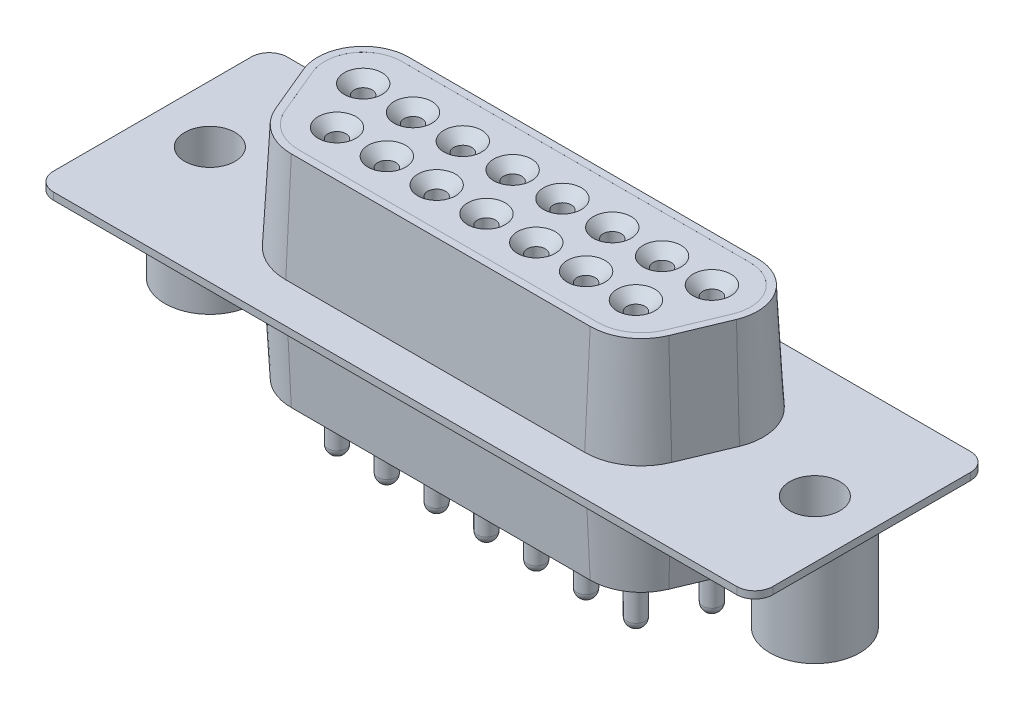
from build123d import *

# Parameters (mm, degrees)
BASE_EXTRUDE_DEPTH           = 5.91
BASE_EXTRUDE_DRAFT           = 3
BOSS_EXTRUDE1_DEPTH          = 0.2
CUT_EXTRUDE1_DEPTH           = 0.001
SKETCH4_R                    = 0.5
CUT_EXTRUDE5_DEPTH           = 6
SKETCH5_R                    = 0.5
BOSS_EXTRUDE5_DEPTH          = 3
DOME3_FACE_RADIUS            = 0.5
DOME3_HEIGHT                 = 0.5
CHAMFER1_SIZE                = 0.55
LPATTERN1_COUNT              = 8
LPATTERN1_PITCH              = 2.77
LPATTERN1_COPY_1_FACE_RADIUS = 0.5
LPATTERN1_COPY_1_HEIGHT      = 0.5
LPATTERN1_COPY_2_FACE_RADIUS = 0.5
LPATTERN1_COPY_2_HEIGHT      = 0.5
LPATTERN1_COPY_3_FACE_RADIUS = 0.5
LPATTERN1_COPY_3_HEIGHT      = 0.5
LPATTERN1_COPY_4_FACE_RADIUS = 0.5
LPATTERN1_COPY_4_HEIGHT      = 0.5
LPATTERN1_COPY_5_FACE_RADIUS = 0.5
LPATTERN1_COPY_5_HEIGHT      = 0.5
LPATTERN1_COPY_6_FACE_RADIUS = 0.5
LPATTERN1_COPY_6_HEIGHT      = 0.5
LPATTERN1_COPY_7_FACE_RADIUS = 0.5
LPATTERN1_COPY_7_HEIGHT      = 0.5
CHAMFER1_OF_LPATTERN1_SIZE   = 0.55
SKETCH6_R                    = 0.5
CUT_EXTRUDE8_DEPTH           = 6
SKETCH7_R                    = 0.5
BOSS_EXTRUDE6_DEPTH          = 3
DOME4_FACE_RADIUS            = 0.5
DOME4_HEIGHT                 = 0.5
CHAMFER3_SIZE                = 0.55
LPATTERN3_COUNT              = 7
LPATTERN3_PITCH              = 2.77
LPATTERN3_COPY_1_FACE_RADIUS = 0.5
LPATTERN3_COPY_1_HEIGHT      = 0.5
LPATTERN3_COPY_2_FACE_RADIUS = 0.5
LPATTERN3_COPY_2_HEIGHT      = 0.5
LPATTERN3_COPY_3_FACE_RADIUS = 0.5
LPATTERN3_COPY_3_HEIGHT      = 0.5
LPATTERN3_COPY_4_FACE_RADIUS = 0.5
LPATTERN3_COPY_4_HEIGHT      = 0.5
LPATTERN3_COPY_5_FACE_RADIUS = 0.5
LPATTERN3_COPY_5_HEIGHT      = 0.5
LPATTERN3_COPY_6_FACE_RADIUS = 0.5
LPATTERN3_COPY_6_HEIGHT      = 0.5
CHAMFER3_OF_LPATTERN3_SIZE   = 0.55
SKETCH8_R                    = 2.5
BOSS_EXTRUDE4_DEPTH          = 5.9
SKETCH9_R                    = 1.4
CUT_EXTRUDE4_DEPTH           = 34.06967682


with BuildPart() as part:
    # Sketch1 → Base-Extrude (with draft: the straight prism first)
    with BuildSketch(Plane(origin=(0, 0, 0), x_dir=(1, 0, 0), z_dir=(0, 1, 0))):
        with BuildLine():
            ThreePointArc((0, 2.54), (-2.113784333, 1.408373457), (-2.344092715, -0.97817654))
            Line((-2.344092715, -0.97817654), (-1.23595406, -3.633709202))
            ThreePointArc((-1.23595406, -3.633709202), (-0.189716779, -4.9034439), (1.385, -5.38))
            Line((1.385, -5.38), (18.005, -5.38))
            ThreePointArc((18.005, -5.38), (19.579716779, -4.9034439), (20.62595406, -3.633709202))
            Line((20.62595406, -3.633709202), (21.734092715, -0.97817654))
            ThreePointArc((21.734092715, -0.97817654), (21.503784333, 1.408373457), (19.39, 2.54))
            Line((19.39, 2.54), (0, 2.54))
        make_face()
    extrude(amount=-BASE_EXTRUDE_DEPTH)
    # Base-Extrude: the draft: its side faces are tilted about the plane it starts from
    base_extrude_sides = [part.faces().sort_by_distance(p)[0] for p in [
        (9.695, -2.955, -2.54),
        (-2.113784333, -2.955, -1.408373457),
        (-1.790023387, -2.955, 2.305942871),
        (-0.189716779, -2.955, 4.9034439),
        (9.695, -2.955, 5.38),
        (19.579716779, -2.955, 4.9034439),
        (21.180023387, -2.955, 2.305942871),
        (21.503784333, -2.955, -1.408373457),
    ]]
    draft(base_extrude_sides, Plane(origin=(0, 0, 0), x_dir=(1, 0, 0), z_dir=(0, 1, 0)), BASE_EXTRUDE_DRAFT)

    # Sketch2 → Boss-Extrude1 (add)
    with BuildSketch(Plane.XZ.offset(5.91)):
        with BuildLine():
            Line((28.695, 7.92), (-9.305, 7.92))
            ThreePointArc((-9.305, 7.92), (-10.012106781, 7.627106781), (-10.305, 6.92))
            Line((-10.305, 6.92), (-10.305, -4.08))
            ThreePointArc((-10.305, -4.08), (-10.012106781, -4.787106781), (-9.305, -5.08))
            Line((-9.305, -5.08), (28.695, -5.08))
            ThreePointArc((28.695, -5.08), (29.402106781, -4.787106781), (29.695, -4.08))
            Line((29.695, -4.08), (29.695, 6.92))
            ThreePointArc((29.695, 6.92), (29.402106781, 7.627106781), (28.695, 7.92))
        make_face()
    extrude(amount=BOSS_EXTRUDE1_DEPTH)

    # Sketch3 → Cut-Extrude1 (cut)
    with BuildSketch(Plane(origin=(0, 0, 0), x_dir=(-1, 0, 0), z_dir=(0, 1, 0))):
        with BuildLine():
            Line((-19.39, -2.14), (0, -2.14))
            ThreePointArc((0, -2.14), (1.78090491, -1.186582362), (1.974944256, 0.82413299))
            Line((1.974944256, 0.82413299), (0.8668056, 3.479665652))
            ThreePointArc((0.8668056, 3.479665652), (-0.032074317, 4.570564477), (-1.385, 4.98))
            Line((-1.385, 4.98), (-18.005, 4.98))
            ThreePointArc((-18.005, 4.98), (-19.357925683, 4.570564477), (-20.2568056, 3.479665652))
            Line((-20.2568056, 3.479665652), (-21.364944256, 0.82413299))
            ThreePointArc((-21.364944256, 0.82413299), (-21.17090491, -1.186582362), (-19.39, -2.14))
        make_face()
    extrude(amount=-CUT_EXTRUDE1_DEPTH, mode=Mode.SUBTRACT)

    # Boss-Mirror1: part across plane


with BuildPart() as part_1:
    add(part.part)
    add(part.part.mirror(Plane(origin=(28.695, -6.11, 6.92), x_dir=(0, 0, 1), z_dir=(0, -1, 0))))

    # Sketch4 → Cut-Extrude5 (cut)
    with BuildSketch(Plane(origin=(0, -0.001, 0), x_dir=(-1, 0, 0), z_dir=(0, 1, 0))):
        with Locations(Location((0, 0, 0), (0, 0, 90))):
            Circle(SKETCH4_R)
    cut_extrude5 = extrude(amount=-CUT_EXTRUDE5_DEPTH, mode=Mode.SUBTRACT)

    # Sketch5 → Boss-Extrude5 (add)
    with BuildSketch(Plane.XZ.offset(12.219)):
        with Locations(Location((0, 0, 0), (0, 0, 90))):
            Circle(SKETCH5_R)
    boss_extrude5 = extrude(amount=BOSS_EXTRUDE5_DEPTH)

    # Dome3: a dome of height H over a round flat face of radius A is a cap of a sphere of radius (A * A + H * H) / (2 * H)
    dome3_r = (DOME3_FACE_RADIUS * DOME3_FACE_RADIUS + DOME3_HEIGHT * DOME3_HEIGHT) / (2 * DOME3_HEIGHT)
    dome3_base = Plane((0, -15.219, 0), z_dir=(0, -1, 0))
    with Locations(dome3_base.offset(DOME3_HEIGHT - dome3_r)):
        dome3_ball = Sphere(dome3_r, mode=Mode.PRIVATE)
    add(split(dome3_ball, bisect_by=dome3_base, keep=Keep.TOP, mode=Mode.PRIVATE))

    # Chamfer1
    chamfer1_edges = [part_1.edges().sort_by_distance(p)[0] for p in [
        (0, -0.001, -0.5),
    ]]
    chamfer(chamfer1_edges, length=CHAMFER1_SIZE)

    # LPattern1: Cut-Extrude5, Boss-Extrude5 ×8
    with Locations(*[(i * LPATTERN1_PITCH, 0, 0) for i in range(1, LPATTERN1_COUNT)]):
        add(cut_extrude5, mode=Mode.SUBTRACT)
        add(boss_extrude5)

    # LPattern1 copy 1: a dome of height H over a round flat face of radius A is a cap of a sphere of radius (A * A + H * H) / (2 * H)
    lpattern1_copy_1_r = (LPATTERN1_COPY_1_FACE_RADIUS * LPATTERN1_COPY_1_FACE_RADIUS + LPATTERN1_COPY_1_HEIGHT * LPATTERN1_COPY_1_HEIGHT) / (2 * LPATTERN1_COPY_1_HEIGHT)
    lpattern1_copy_1_base = Plane((2.77, -15.219, 0), z_dir=(0, -1, 0))
    with Locations(lpattern1_copy_1_base.offset(LPATTERN1_COPY_1_HEIGHT - lpattern1_copy_1_r)):
        lpattern1_copy_1_ball = Sphere(lpattern1_copy_1_r, mode=Mode.PRIVATE)
    add(split(lpattern1_copy_1_ball, bisect_by=lpattern1_copy_1_base, keep=Keep.TOP, mode=Mode.PRIVATE))

    # LPattern1 copy 2: a dome of height H over a round flat face of radius A is a cap of a sphere of radius (A * A + H * H) / (2 * H)
    lpattern1_copy_2_r = (LPATTERN1_COPY_2_FACE_RADIUS * LPATTERN1_COPY_2_FACE_RADIUS + LPATTERN1_COPY_2_HEIGHT * LPATTERN1_COPY_2_HEIGHT) / (2 * LPATTERN1_COPY_2_HEIGHT)
    lpattern1_copy_2_base = Plane((5.54, -15.219, 0), z_dir=(0, -1, 0))
    with Locations(lpattern1_copy_2_base.offset(LPATTERN1_COPY_2_HEIGHT - lpattern1_copy_2_r)):
        lpattern1_copy_2_ball = Sphere(lpattern1_copy_2_r, mode=Mode.PRIVATE)
    add(split(lpattern1_copy_2_ball, bisect_by=lpattern1_copy_2_base, keep=Keep.TOP, mode=Mode.PRIVATE))

    # LPattern1 copy 3: a dome of height H over a round flat face of radius A is a cap of a sphere of radius (A * A + H * H) / (2 * H)
    lpattern1_copy_3_r = (LPATTERN1_COPY_3_FACE_RADIUS * LPATTERN1_COPY_3_FACE_RADIUS + LPATTERN1_COPY_3_HEIGHT * LPATTERN1_COPY_3_HEIGHT) / (2 * LPATTERN1_COPY_3_HEIGHT)
    lpattern1_copy_3_base = Plane((8.31, -15.219, 0), z_dir=(0, -1, 0))
    with Locations(lpattern1_copy_3_base.offset(LPATTERN1_COPY_3_HEIGHT - lpattern1_copy_3_r)):
        lpattern1_copy_3_ball = Sphere(lpattern1_copy_3_r, mode=Mode.PRIVATE)
    add(split(lpattern1_copy_3_ball, bisect_by=lpattern1_copy_3_base, keep=Keep.TOP, mode=Mode.PRIVATE))

    # LPattern1 copy 4: a dome of height H over a round flat face of radius A is a cap of a sphere of radius (A * A + H * H) / (2 * H)
    lpattern1_copy_4_r = (LPATTERN1_COPY_4_FACE_RADIUS * LPATTERN1_COPY_4_FACE_RADIUS + LPATTERN1_COPY_4_HEIGHT * LPATTERN1_COPY_4_HEIGHT) / (2 * LPATTERN1_COPY_4_HEIGHT)
    lpattern1_copy_4_base = Plane((11.08, -15.219, 0), z_dir=(0, -1, 0))
    with Locations(lpattern1_copy_4_base.offset(LPATTERN1_COPY_4_HEIGHT - lpattern1_copy_4_r)):
        lpattern1_copy_4_ball = Sphere(lpattern1_copy_4_r, mode=Mode.PRIVATE)
    add(split(lpattern1_copy_4_ball, bisect_by=lpattern1_copy_4_base, keep=Keep.TOP, mode=Mode.PRIVATE))

    # LPattern1 copy 5: a dome of height H over a round flat face of radius A is a cap of a sphere of radius (A * A + H * H) / (2 * H)
    lpattern1_copy_5_r = (LPATTERN1_COPY_5_FACE_RADIUS * LPATTERN1_COPY_5_FACE_RADIUS + LPATTERN1_COPY_5_HEIGHT * LPATTERN1_COPY_5_HEIGHT) / (2 * LPATTERN1_COPY_5_HEIGHT)
    lpattern1_copy_5_base = Plane((13.85, -15.219, 0), z_dir=(0, -1, 0))
    with Locations(lpattern1_copy_5_base.offset(LPATTERN1_COPY_5_HEIGHT - lpattern1_copy_5_r)):
        lpattern1_copy_5_ball = Sphere(lpattern1_copy_5_r, mode=Mode.PRIVATE)
    add(split(lpattern1_copy_5_ball, bisect_by=lpattern1_copy_5_base, keep=Keep.TOP, mode=Mode.PRIVATE))

    # LPattern1 copy 6: a dome of height H over a round flat face of radius A is a cap of a sphere of radius (A * A + H * H) / (2 * H)
    lpattern1_copy_6_r = (LPATTERN1_COPY_6_FACE_RADIUS * LPATTERN1_COPY_6_FACE_RADIUS + LPATTERN1_COPY_6_HEIGHT * LPATTERN1_COPY_6_HEIGHT) / (2 * LPATTERN1_COPY_6_HEIGHT)
    lpattern1_copy_6_base = Plane((16.62, -15.219, 0), z_dir=(0, -1, 0))
    with Locations(lpattern1_copy_6_base.offset(LPATTERN1_COPY_6_HEIGHT - lpattern1_copy_6_r)):
        lpattern1_copy_6_ball = Sphere(lpattern1_copy_6_r, mode=Mode.PRIVATE)
    add(split(lpattern1_copy_6_ball, bisect_by=lpattern1_copy_6_base, keep=Keep.TOP, mode=Mode.PRIVATE))

    # LPattern1 copy 7: a dome of height H over a round flat face of radius A is a cap of a sphere of radius (A * A + H * H) / (2 * H)
    lpattern1_copy_7_r = (LPATTERN1_COPY_7_FACE_RADIUS * LPATTERN1_COPY_7_FACE_RADIUS + LPATTERN1_COPY_7_HEIGHT * LPATTERN1_COPY_7_HEIGHT) / (2 * LPATTERN1_COPY_7_HEIGHT)
    lpattern1_copy_7_base = Plane((19.39, -15.219, 0), z_dir=(0, -1, 0))
    with Locations(lpattern1_copy_7_base.offset(LPATTERN1_COPY_7_HEIGHT - lpattern1_copy_7_r)):
        lpattern1_copy_7_ball = Sphere(lpattern1_copy_7_r, mode=Mode.PRIVATE)
    add(split(lpattern1_copy_7_ball, bisect_by=lpattern1_copy_7_base, keep=Keep.TOP, mode=Mode.PRIVATE))

    # Chamfer1 of LPattern1
    chamfer1_of_lpattern1_edges = [part_1.edges().sort_by_distance(p)[0] for p in [
        (2.77, -0.001, -0.5),
        (5.54, -0.001, -0.5),
        (8.31, -0.001, -0.5),
        (11.08, -0.001, -0.5),
        (13.85, -0.001, -0.5),
        (16.62, -0.001, -0.5),
        (19.39, -0.001, -0.5),
    ]]
    chamfer(chamfer1_of_lpattern1_edges, length=CHAMFER1_OF_LPATTERN1_SIZE)

    # Sketch6 → Cut-Extrude8 (cut)
    with BuildSketch(Plane(origin=(0, -0.001, 0), x_dir=(-1, 0, 0), z_dir=(0, 1, 0))):
        with Locations(Location((-1.385, 2.84, 0), (0, 0, 90))):
            Circle(SKETCH6_R)
    cut_extrude8 = extrude(amount=-CUT_EXTRUDE8_DEPTH, mode=Mode.SUBTRACT)

    # Sketch7 → Boss-Extrude6 (add)
    with BuildSketch(Plane.XZ.offset(12.219)):
        with Locations(Location((1.385, 2.84, 0), (0, 0, 90))):
            Circle(SKETCH7_R)
    boss_extrude6 = extrude(amount=BOSS_EXTRUDE6_DEPTH)

    # Dome4: a dome of height H over a round flat face of radius A is a cap of a sphere of radius (A * A + H * H) / (2 * H)
    dome4_r = (DOME4_FACE_RADIUS * DOME4_FACE_RADIUS + DOME4_HEIGHT * DOME4_HEIGHT) / (2 * DOME4_HEIGHT)
    dome4_base = Plane((1.385, -15.219, 2.84), z_dir=(0, -1, 0))
    with Locations(dome4_base.offset(DOME4_HEIGHT - dome4_r)):
        dome4_ball = Sphere(dome4_r, mode=Mode.PRIVATE)
    add(split(dome4_ball, bisect_by=dome4_base, keep=Keep.TOP, mode=Mode.PRIVATE))

    # Chamfer3
    chamfer3_edges = [part_1.edges().sort_by_distance(p)[0] for p in [
        (1.385, -0.001, 2.34),
    ]]
    chamfer(chamfer3_edges, length=CHAMFER3_SIZE)

    # LPattern3: Cut-Extrude8, Boss-Extrude6 ×7
    with Locations(*[(i * LPATTERN3_PITCH, 0, 0) for i in range(1, LPATTERN3_COUNT)]):
        add(cut_extrude8, mode=Mode.SUBTRACT)
        add(boss_extrude6)

    # LPattern3 copy 1: a dome of height H over a round flat face of radius A is a cap of a sphere of radius (A * A + H * H) / (2 * H)
    lpattern3_copy_1_r = (LPATTERN3_COPY_1_FACE_RADIUS * LPATTERN3_COPY_1_FACE_RADIUS + LPATTERN3_COPY_1_HEIGHT * LPATTERN3_COPY_1_HEIGHT) / (2 * LPATTERN3_COPY_1_HEIGHT)
    lpattern3_copy_1_base = Plane((4.155, -15.219, 2.84), z_dir=(0, -1, 0))
    with Locations(lpattern3_copy_1_base.offset(LPATTERN3_COPY_1_HEIGHT - lpattern3_copy_1_r)):
        lpattern3_copy_1_ball = Sphere(lpattern3_copy_1_r, mode=Mode.PRIVATE)
    add(split(lpattern3_copy_1_ball, bisect_by=lpattern3_copy_1_base, keep=Keep.TOP, mode=Mode.PRIVATE))

    # LPattern3 copy 2: a dome of height H over a round flat face of radius A is a cap of a sphere of radius (A * A + H * H) / (2 * H)
    lpattern3_copy_2_r = (LPATTERN3_COPY_2_FACE_RADIUS * LPATTERN3_COPY_2_FACE_RADIUS + LPATTERN3_COPY_2_HEIGHT * LPATTERN3_COPY_2_HEIGHT) / (2 * LPATTERN3_COPY_2_HEIGHT)
    lpattern3_copy_2_base = Plane((6.925, -15.219, 2.84), z_dir=(0, -1, 0))
    with Locations(lpattern3_copy_2_base.offset(LPATTERN3_COPY_2_HEIGHT - lpattern3_copy_2_r)):
        lpattern3_copy_2_ball = Sphere(lpattern3_copy_2_r, mode=Mode.PRIVATE)
    add(split(lpattern3_copy_2_ball, bisect_by=lpattern3_copy_2_base, keep=Keep.TOP, mode=Mode.PRIVATE))

    # LPattern3 copy 3: a dome of height H over a round flat face of radius A is a cap of a sphere of radius (A * A + H * H) / (2 * H)
    lpattern3_copy_3_r = (LPATTERN3_COPY_3_FACE_RADIUS * LPATTERN3_COPY_3_FACE_RADIUS + LPATTERN3_COPY_3_HEIGHT * LPATTERN3_COPY_3_HEIGHT) / (2 * LPATTERN3_COPY_3_HEIGHT)
    lpattern3_copy_3_base = Plane((9.695, -15.219, 2.84), z_dir=(0, -1, 0))
    with Locations(lpattern3_copy_3_base.offset(LPATTERN3_COPY_3_HEIGHT - lpattern3_copy_3_r)):
        lpattern3_copy_3_ball = Sphere(lpattern3_copy_3_r, mode=Mode.PRIVATE)
    add(split(lpattern3_copy_3_ball, bisect_by=lpattern3_copy_3_base, keep=Keep.TOP, mode=Mode.PRIVATE))

    # LPattern3 copy 4: a dome of height H over a round flat face of radius A is a cap of a sphere of radius (A * A + H * H) / (2 * H)
    lpattern3_copy_4_r = (LPATTERN3_COPY_4_FACE_RADIUS * LPATTERN3_COPY_4_FACE_RADIUS + LPATTERN3_COPY_4_HEIGHT * LPATTERN3_COPY_4_HEIGHT) / (2 * LPATTERN3_COPY_4_HEIGHT)
    lpattern3_copy_4_base = Plane((12.465, -15.219, 2.84), z_dir=(0, -1, 0))
    with Locations(lpattern3_copy_4_base.offset(LPATTERN3_COPY_4_HEIGHT - lpattern3_copy_4_r)):
        lpattern3_copy_4_ball = Sphere(lpattern3_copy_4_r, mode=Mode.PRIVATE)
    add(split(lpattern3_copy_4_ball, bisect_by=lpattern3_copy_4_base, keep=Keep.TOP, mode=Mode.PRIVATE))

    # LPattern3 copy 5: a dome of height H over a round flat face of radius A is a cap of a sphere of radius (A * A + H * H) / (2 * H)
    lpattern3_copy_5_r = (LPATTERN3_COPY_5_FACE_RADIUS * LPATTERN3_COPY_5_FACE_RADIUS + LPATTERN3_COPY_5_HEIGHT * LPATTERN3_COPY_5_HEIGHT) / (2 * LPATTERN3_COPY_5_HEIGHT)
    lpattern3_copy_5_base = Plane((15.235, -15.219, 2.84), z_dir=(0, -1, 0))
    with Locations(lpattern3_copy_5_base.offset(LPATTERN3_COPY_5_HEIGHT - lpattern3_copy_5_r)):
        lpattern3_copy_5_ball = Sphere(lpattern3_copy_5_r, mode=Mode.PRIVATE)
    add(split(lpattern3_copy_5_ball, bisect_by=lpattern3_copy_5_base, keep=Keep.TOP, mode=Mode.PRIVATE))

    # LPattern3 copy 6: a dome of height H over a round flat face of radius A is a cap of a sphere of radius (A * A + H * H) / (2 * H)
    lpattern3_copy_6_r = (LPATTERN3_COPY_6_FACE_RADIUS * LPATTERN3_COPY_6_FACE_RADIUS + LPATTERN3_COPY_6_HEIGHT * LPATTERN3_COPY_6_HEIGHT) / (2 * LPATTERN3_COPY_6_HEIGHT)
    lpattern3_copy_6_base = Plane((18.005, -15.219, 2.84), z_dir=(0, -1, 0))
    with Locations(lpattern3_copy_6_base.offset(LPATTERN3_COPY_6_HEIGHT - lpattern3_copy_6_r)):
        lpattern3_copy_6_ball = Sphere(lpattern3_copy_6_r, mode=Mode.PRIVATE)
    add(split(lpattern3_copy_6_ball, bisect_by=lpattern3_copy_6_base, keep=Keep.TOP, mode=Mode.PRIVATE))

    # Chamfer3 of LPattern3
    chamfer3_of_lpattern3_edges = [part_1.edges().sort_by_distance(p)[0] for p in [
        (4.155, -0.001, 2.34),
        (6.925, -0.001, 2.34),
        (9.695, -0.001, 2.34),
        (12.465, -0.001, 2.34),
        (15.235, -0.001, 2.34),
        (18.005, -0.001, 2.34),
    ]]
    chamfer(chamfer3_of_lpattern3_edges, length=CHAMFER3_OF_LPATTERN3_SIZE)

    # Sketch8 → Boss-Extrude4 (add)
    with BuildSketch(Plane(origin=(0, -6.31, 0), x_dir=(-1, 0, 0), z_dir=(0, 1, 0))):
        with Locations(Location((-26.515, 1.4, 0), (0, 0, 90))):
            Circle(SKETCH8_R)
    boss_extrude4 = extrude(amount=-BOSS_EXTRUDE4_DEPTH)

    # Sketch9 → Cut-Extrude4 (cut, through all)
    with BuildSketch(Plane.XZ.offset(12.21)):
        with Locations(Location((26.515, 1.4, 0), (0, 0, 270))):
            Circle(SKETCH9_R)
    cut_extrude4 = extrude(amount=-CUT_EXTRUDE4_DEPTH, mode=Mode.SUBTRACT)

    # Mirror1: Boss-Extrude4, Cut-Extrude4 across plane
    add(boss_extrude4.mirror(Plane(origin=(9.695, 0, 0), x_dir=(0, 0, 1), z_dir=(1, 0, 0))))
    add(cut_extrude4.mirror(Plane(origin=(9.695, 0, 0), x_dir=(0, 0, 1), z_dir=(1, 0, 0))), mode=Mode.SUBTRACT)


solid = part_1.part
